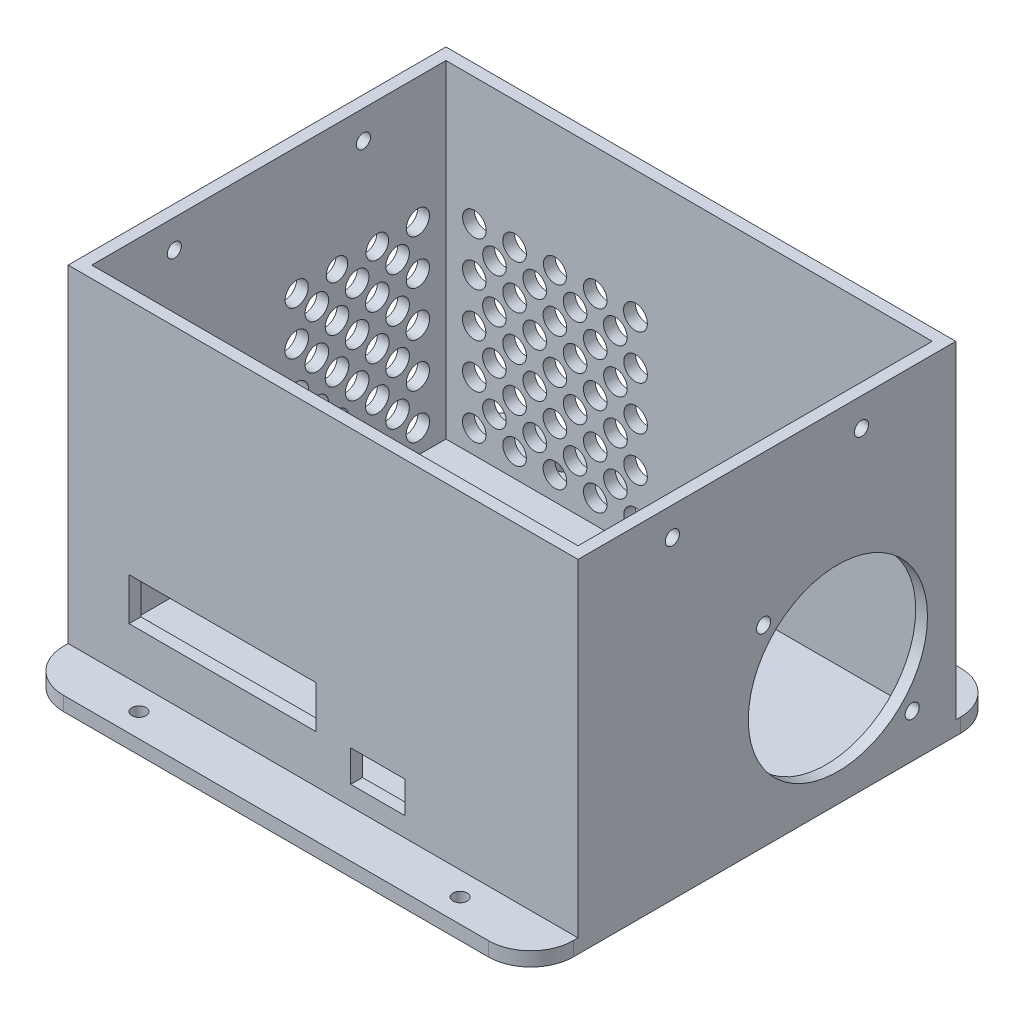
from build123d import *

# Parameters (mm, degrees)
SKETCH1_W                 = 78.1
SKETCH1_H                 = 55.9
BOSS_EXTRUDE1_DEPTH       = 3
SKETCH2_R                 = 1.25
CUT_EXTRUDE1_DEPTH        = 68
SKETCH4_W                 = 82.1
SKETCH4_H                 = 59.9
SKETCH4_W_2               = 78.1
SKETCH4_H_2               = 55.9
BOSS_EXTRUDE3_DEPTH       = 3
SKETCH6_R                 = 3
SKETCH6_R_2               = 1.25
BOSS_EXTRUDE4_DEPTH       = 3.5
SKETCH7_W                 = 82.1
SKETCH7_H                 = 16.2
BOSS_EXTRUDE5_DEPTH       = 3
SKETCH8_W                 = 82.1
SKETCH8_H                 = 50.5
BOSS_EXTRUDE6_DEPTH       = 3
BOSS_EXTRUDE7_DEPTH       = 20
SKETCH12_W                = 79.1
SKETCH12_H                = 50.5
BOSS_EXTRUDE8_DEPTH       = 3
SKETCH17_W                = 105.1
SKETCH17_H                = 50.5
BOSS_EXTRUDE13_DEPTH      = 1
BOSS_EXTRUDE13_DEPTH_BACK = 2
SKETCH18_W                = 11.5
SKETCH18_H                = 7.7
SKETCH18_W_2              = 39.6
SKETCH18_H_2              = 9
CUT_EXTRUDE4_DEPTH        = 9
SKETCH19_W                = 80.1
SKETCH19_H                = 50.5
BOSS_EXTRUDE14_DEPTH      = 3
SKETCH20_R                = 19
SKETCH20_R_2              = 1.5
CUT_EXTRUDE5_DEPTH        = 3
SKETCH22_R                = 2.5
CUT_EXTRUDE6_DEPTH        = 3
SKETCH23_W                = 108.1
SKETCH23_H                = 80.1
SKETCH23_W_2              = 102.1
SKETCH23_H_2              = 74.1
BOSS_EXTRUDE15_DEPTH      = 22
SKETCH24_R                = 1.5
CUT_EXTRUDE7_DEPTH        = 200
SKETCH25_R                = 2.5
CUT_EXTRUDE9_DEPTH        = 13.5
SKETCH26_W                = 103.1
SKETCH26_H                = 75.1
SKETCH26_W_2              = 102.1
SKETCH26_H_2              = 74.1
CUT_EXTRUDE13_DEPTH       = 69.5
SKETCH27_W                = 11.5
SKETCH27_H                = 1
BOSS_EXTRUDE17_DEPTH      = 2.5
SKETCH28_R                = 1.5
BOSS_EXTRUDE18_DEPTH      = 2.5
SKETCH30_R                = 2.5
SKETCH30_R_2              = 2.477942284
SKETCH30_R_3              = 2.503123049
SKETCH30_R_4              = 2.526952657
SKETCH30_R_5              = 2.451627817
CUT_EXTRUDE14_DEPTH       = 2.5
SKETCH32_W                = 38.749491288
SKETCH32_H                = 51.597296514
BOSS_EXTRUDE19_DEPTH      = 2.5
SKETCH33_R                = 2.482139688
SKETCH33_R_2              = 2.454549158
SKETCH33_R_3              = 2.5
SKETCH33_R_4              = 2.455770757
SKETCH33_R_5              = 2.390033197
SKETCH33_R_6              = 2.277845443
SKETCH33_R_7              = 2.451954558
CUT_EXTRUDE15_DEPTH       = 2.5
SKETCH34_W                = 108.1
SKETCH34_H                = 3
BOSS_EXTRUDE20_DEPTH      = 10
SKETCH35_W                = 108.1
SKETCH35_H                = 3
BOSS_EXTRUDE21_DEPTH      = 10
SKETCH36_R                = 1.5
CUT_EXTRUDE16_DEPTH       = 10
FILLET2_R                 = 9


with BuildPart() as part:
    # Sketch1 → Boss-Extrude1 (new body)
    with BuildSketch(Plane(origin=(0, 0, 0), x_dir=(1, 0, 0), z_dir=(0, 1, 0))):
        Rectangle(SKETCH1_W, SKETCH1_H)
    extrude(amount=BOSS_EXTRUDE1_DEPTH)

    # Sketch2 → Cut-Extrude1 (cut)
    with BuildSketch(Plane(origin=(0, 3, 0), x_dir=(1, 0, 0), z_dir=(0, 1, 0))):
        with Locations((-35.9, 20.9)):
            Circle(SKETCH2_R)
        with Locations((-35.9, -24.8)):
            Circle(SKETCH2_R)
        with Locations((35.9, -24.8)):
            Circle(SKETCH2_R)
        with Locations((35.9, 24.8)):
            Circle(SKETCH2_R)
    extrude(amount=-CUT_EXTRUDE1_DEPTH, mode=Mode.SUBTRACT)

    # Sketch4 → Boss-Extrude3 (add)
    with BuildSketch(Plane(origin=(0, 0, 0), x_dir=(-1, 0, 0), z_dir=(0, -1, 0))):
        Rectangle(SKETCH4_W, SKETCH4_H)
        Rectangle(SKETCH4_W_2, SKETCH4_H_2, mode=Mode.SUBTRACT)
    extrude(amount=-BOSS_EXTRUDE3_DEPTH)

    # Sketch6 → Boss-Extrude4 (add)
    with BuildSketch(Plane(origin=(0, 3, 0), x_dir=(1, 0, 0), z_dir=(0, 1, 0))):
        with Locations((-35.9, 20.9)):
            Circle(SKETCH6_R)
        with Locations((-35.9, 20.9)):
            Circle(SKETCH6_R_2, mode=Mode.SUBTRACT)
        with Locations((35.9, 24.8)):
            Circle(SKETCH6_R)
        with Locations((35.9, 24.8)):
            Circle(SKETCH6_R_2, mode=Mode.SUBTRACT)
        with Locations((35.9, -24.8)):
            Circle(SKETCH6_R)
        with Locations((35.9, -24.8)):
            Circle(SKETCH6_R_2, mode=Mode.SUBTRACT)
        with Locations((-35.9, -24.8)):
            Circle(SKETCH6_R)
        with Locations((-35.9, -24.8)):
            Circle(SKETCH6_R_2, mode=Mode.SUBTRACT)
    extrude(amount=BOSS_EXTRUDE4_DEPTH)

    # Sketch7 → Boss-Extrude5 (add)
    with BuildSketch(Plane(origin=(0, 0, 0), x_dir=(-1, 0, 0), z_dir=(0, -1, 0))):
        with Locations((0, 38.05)):
            Rectangle(SKETCH7_W, SKETCH7_H)
    extrude(amount=-BOSS_EXTRUDE5_DEPTH)

    # Sketch8 → Boss-Extrude6 (add)
    with BuildSketch(Plane(origin=(0, 0, -46.15), x_dir=(-1, 0, 0), z_dir=(0, 0, -1))):
        with Locations((0, 25.25)):
            Rectangle(SKETCH8_W, SKETCH8_H)
    extrude(amount=BOSS_EXTRUDE6_DEPTH)

    # Sketch10 → Boss-Extrude7 (add)
    with BuildSketch(Plane(origin=(41.05, 0, 0), x_dir=(0, 0, -1), z_dir=(1, 0, 0))):
        Polygon((49.15, 50.5), (46.15, 50.5), (46.15, 3), (-29.95, 3), (-29.95, 0), (49.15, 0), align=None)
    extrude(amount=BOSS_EXTRUDE7_DEPTH)

    # Sketch12 → Boss-Extrude8 (add)
    with BuildSketch(Plane.ZY.offset(41.05)):
        with Locations((-9.6, 25.25)):
            Rectangle(SKETCH12_W, SKETCH12_H)
    extrude(amount=BOSS_EXTRUDE8_DEPTH)

    # Sketch17 → Boss-Extrude13 (add, two sides)
    with BuildSketch(Plane.XY.offset(29.95)) as boss_extrude13_sk:
        with Locations((8.5, 25.25)):
            Rectangle(SKETCH17_W, SKETCH17_H)
    extrude(amount=BOSS_EXTRUDE13_DEPTH)
    extrude(boss_extrude13_sk.sketch, amount=-BOSS_EXTRUDE13_DEPTH_BACK)

    # Sketch18 → Cut-Extrude4 (cut)
    with BuildSketch(Plane(origin=(0, 0, 27.95), x_dir=(-1, 0, 0), z_dir=(0, 0, -1))):
        with Locations((-21.6, 9.95)):
            Rectangle(SKETCH18_W, SKETCH18_H)
        with Locations((11.35, 17.6)):
            Rectangle(SKETCH18_W_2, SKETCH18_H_2)
    extrude(amount=-CUT_EXTRUDE4_DEPTH, mode=Mode.SUBTRACT)

    # Sketch19 → Boss-Extrude14 (add)
    with BuildSketch(Plane(origin=(61.05, 0, 0), x_dir=(0, 0, -1), z_dir=(1, 0, 0))):
        with Locations((9.1, 25.25)):
            Rectangle(SKETCH19_W, SKETCH19_H)
    extrude(amount=BOSS_EXTRUDE14_DEPTH)

    # Sketch20 → Cut-Extrude5 (cut)
    with BuildSketch(Plane.ZY.offset(-61.05)):
        with Locations((-24.15, 25)):
            Circle(SKETCH20_R)
        with Locations((-8.4, 40.75)):
            Circle(SKETCH20_R_2)
        with Locations((-39.9, 40.75)):
            Circle(SKETCH20_R_2)
        with Locations((-8.4, 9.25)):
            Circle(SKETCH20_R_2)
        with Locations((-39.9, 9.25)):
            Circle(SKETCH20_R_2)
    extrude(amount=-CUT_EXTRUDE5_DEPTH, mode=Mode.SUBTRACT)

    # Sketch22 → Cut-Extrude6 (cut)
    with BuildSketch(Plane(origin=(-41.05, 0, 0), x_dir=(0, 0, -1), z_dir=(1, 0, 0))):
        with Locations((14.225, 12.6875)):
            Circle(SKETCH22_R)
        with Locations((14.225, 22.0625)):
            Circle(SKETCH22_R)
        with Locations((18.5, 17.375)):
            Circle(SKETCH22_R)
        with Locations((22.775, 22.0625)):
            Circle(SKETCH22_R)
        with Locations((22.775, 12.6875)):
            Circle(SKETCH22_R)
        with Locations((14.225, 31.4375)):
            Circle(SKETCH22_R)
        with Locations((18.5, 26.75)):
            Circle(SKETCH22_R)
        with Locations((22.775, 31.4375)):
            Circle(SKETCH22_R)
        with Locations((18.5, 36.125)):
            Circle(SKETCH22_R)
        with Locations((14.225, 40.8125)):
            Circle(SKETCH22_R)
        with Locations((22.775, 40.8125)):
            Circle(SKETCH22_R)
        with Locations((27.05, 36.125)):
            Circle(SKETCH22_R)
        with Locations((31.325, 40.8125)):
            Circle(SKETCH22_R)
        with Locations((39.875, 40.8125)):
            Circle(SKETCH22_R)
        with Locations((35.6, 36.125)):
            Circle(SKETCH22_R)
        with Locations((39.875, 31.4375)):
            Circle(SKETCH22_R)
        with Locations((31.325, 31.4375)):
            Circle(SKETCH22_R)
        with Locations((27.05, 26.75)):
            Circle(SKETCH22_R)
        with Locations((31.325, 22.0625)):
            Circle(SKETCH22_R)
        with Locations((39.875, 22.0625)):
            Circle(SKETCH22_R)
        with Locations((35.6, 26.75)):
            Circle(SKETCH22_R)
        with Locations((27.05, 17.375)):
            Circle(SKETCH22_R)
        with Locations((31.325, 12.6875)):
            Circle(SKETCH22_R)
        with Locations((39.875, 12.6875)):
            Circle(SKETCH22_R)
        with Locations((35.6, 17.375)):
            Circle(SKETCH22_R)
        with Locations((18.5, 8)):
            Circle(SKETCH22_R)
        with Locations((27.05, 8)):
            Circle(SKETCH22_R)
        with Locations((35.6, 8)):
            Circle(SKETCH22_R)
    extrude(amount=-CUT_EXTRUDE6_DEPTH, mode=Mode.SUBTRACT)

    # Sketch23 → Boss-Extrude15 (add)
    with BuildSketch(Plane(origin=(0, 50.5, 0), x_dir=(1, 0, 0), z_dir=(0, 1, 0))):
        with Locations((10, 9.1)):
            Rectangle(SKETCH23_W, SKETCH23_H)
        with Locations((10, 9.1)):
            Rectangle(SKETCH23_W_2, SKETCH23_H_2, mode=Mode.SUBTRACT)
    extrude(amount=BOSS_EXTRUDE15_DEPTH)

    # Sketch24 → Cut-Extrude7 (cut)
    with BuildSketch(Plane.ZY.offset(44.05)):
        with Locations((-29.15, 66.5)):
            Circle(SKETCH24_R)
        with Locations((10.95, 66.5)):
            Circle(SKETCH24_R)
    extrude(amount=-CUT_EXTRUDE7_DEPTH, mode=Mode.SUBTRACT)

    # Sketch25 → Cut-Extrude9 (cut)
    with BuildSketch(Plane.ZY.offset(44.05)):
        with Locations((-35.6, 45.5)):
            Circle(SKETCH25_R)
        with Locations((-27.05, 45.5)):
            Circle(SKETCH25_R)
        with Locations((-18.5, 45.5)):
            Circle(SKETCH25_R)
    extrude(amount=-CUT_EXTRUDE9_DEPTH, mode=Mode.SUBTRACT)

    # Sketch26 → Cut-Extrude13 (cut)
    with BuildSketch(Plane(origin=(0, 72.5, 0), x_dir=(1, 0, 0), z_dir=(0, 1, 0))):
        with Locations((10, 9.1)):
            Rectangle(SKETCH26_W, SKETCH26_H)
        with Locations((10, 9.1)):
            Rectangle(SKETCH26_W_2, SKETCH26_H_2, mode=Mode.SUBTRACT)
    extrude(amount=-CUT_EXTRUDE13_DEPTH, mode=Mode.SUBTRACT)

    # Sketch27 → Boss-Extrude17 (add)
    with BuildSketch(Plane.XY.offset(30.95)):
        with Locations((21.6, 6.6)):
            Rectangle(SKETCH27_W, SKETCH27_H)
    extrude(amount=-BOSS_EXTRUDE17_DEPTH)

    # Sketch28 → Boss-Extrude18 (add)
    with BuildSketch(Plane(origin=(64.05, 0, 0), x_dir=(0, 0, -1), z_dir=(1, 0, 0))):
        with Locations((39.9, 40.75)):
            Circle(SKETCH28_R)
        with Locations((8.4, 9.25)):
            Circle(SKETCH28_R)
    extrude(amount=-BOSS_EXTRUDE18_DEPTH)

    # Sketch30 → Cut-Extrude14 (cut)
    with BuildSketch(Plane(origin=(0, 0, -49.15), x_dir=(-1, 0, 0), z_dir=(0, 0, -1))):
        with Locations((35.55, 8)):
            Circle(SKETCH30_R)
        with Locations((27, 8)):
            Circle(SKETCH30_R)
        with Locations((18.45, 8)):
            Circle(SKETCH30_R)
        with Locations((9.9, 8)):
            Circle(SKETCH30_R)
        with Locations((1.35, 8)):
            Circle(SKETCH30_R)
        with Locations((5.61949352, 12.693537807)):
            Circle(SKETCH30_R)
        with Locations((14.16949352, 12.693537807)):
            Circle(SKETCH30_R)
        with Locations((22.725, 12.6875)):
            Circle(SKETCH30_R)
        with Locations((31.275, 12.6875)):
            Circle(SKETCH30_R)
        with Locations((27, 17.375)):
            Circle(SKETCH30_R)
        with Locations((35.55, 17.375)):
            Circle(SKETCH30_R)
        with Locations((35.572057716, 26.774186092)):
            Circle(SKETCH30_R_2)
        with Locations((35.55, 36.125)):
            Circle(SKETCH30_R_3)
        with Locations((35.525916159, 45.521964463)):
            Circle(SKETCH30_R)
        with Locations((1.35, 17.375)):
            Circle(SKETCH30_R)
        with Locations((1.327942284, 26.774186092)):
            Circle(SKETCH30_R_2)
        with Locations((1.35, 36.125)):
            Circle(SKETCH30_R)
        with Locations((1.376952657, 45.524580823)):
            Circle(SKETCH30_R_4)
        with Locations((18.45, 45.548372183)):
            Circle(SKETCH30_R_5)
        with Locations((9.9, 45.5)):
            Circle(SKETCH30_R)
        with Locations((27, 45.5)):
            Circle(SKETCH30_R)
        with Locations((27, 36.173372183)):
            Circle(SKETCH30_R)
        with Locations((18.452627468, 36.176253179)):
            Circle(SKETCH30_R)
        with Locations((9.902627468, 36.176253179)):
            Circle(SKETCH30_R)
        with Locations((9.902627468, 26.801253179)):
            Circle(SKETCH30_R)
        with Locations((18.452627468, 26.801253179)):
            Circle(SKETCH30_R)
        with Locations((27, 26.75)):
            Circle(SKETCH30_R)
        with Locations((18.45, 17.375)):
            Circle(SKETCH30_R)
        with Locations((9.88898704, 17.387075614)):
            Circle(SKETCH30_R)
        with Locations((5.608464662, 22.080630853)):
            Circle(SKETCH30_R)
        with Locations((14.170807254, 22.094164396)):
            Circle(SKETCH30_R)
        with Locations((22.726313734, 22.088126589)):
            Circle(SKETCH30_R)
        with Locations((31.286028858, 22.074593046)):
            Circle(SKETCH30_R)
        with Locations((31.286028858, 31.473779137)):
            Circle(SKETCH30_R)
        with Locations((31.26295808, 40.847668323)):
            Circle(SKETCH30_R)
        with Locations((22.725, 40.8125)):
            Circle(SKETCH30_R)
        with Locations((22.726313734, 31.487312681)):
            Circle(SKETCH30_R)
        with Locations((14.177627468, 31.488753179)):
            Circle(SKETCH30_R)
        with Locations((14.176313734, 40.862312681)):
            Circle(SKETCH30_R)
        with Locations((5.639790062, 40.850417001)):
            Circle(SKETCH30_R)
        with Locations((5.615284876, 31.475219635)):
            Circle(SKETCH30_R)
    extrude(amount=-CUT_EXTRUDE14_DEPTH, mode=Mode.SUBTRACT)

    # Sketch32 → Boss-Extrude19 (add)
    with BuildSketch(Plane.ZY.offset(44.05)):
        with Locations((-25.509986605, 28.814988894)):
            Rectangle(SKETCH32_W, SKETCH32_H)
    extrude(amount=-BOSS_EXTRUDE19_DEPTH)

    # Sketch33 → Cut-Extrude15 (cut)
    with BuildSketch(Plane.ZY.offset(44.05)):
        with Locations((-40.690817502, 8.026993726)):
            Circle(SKETCH33_R)
        with Locations((-40.690817502, 17.480391526)):
            Circle(SKETCH33_R_2)
        with Locations((-40.690817502, 26.876134795)):
            Circle(SKETCH33_R_3)
        with Locations((-40.690817502, 36.327449599)):
            Circle(SKETCH33_R_4)
        with Locations((-40.690817502, 45.834664619)):
            Circle(SKETCH33_R_2)
        with Locations((-32.095987762, 45.609966803)):
            Circle(SKETCH33_R_5)
        with Locations((-23.545126385, 45.722154557)):
            Circle(SKETCH33_R_6)
        with Locations((-15.001944115, 45.548045442)):
            Circle(SKETCH33_R_7)
        with Locations((-36.391519127, 41.081057109)):
            Circle(SKETCH33_R_3)
        with Locations((-27.818673568, 41.024802078)):
            Circle(SKETCH33_R_3)
        with Locations((-19.272048586, 40.996497097)):
            Circle(SKETCH33_R_3)
        with Locations((-14.998970787, 36.270839637)):
            Circle(SKETCH33_R_3)
        with Locations((-14.999909763, 26.818480265)):
            Circle(SKETCH33_R_3)
        with Locations((-14.997081728, 17.423775422)):
            Circle(SKETCH33_R_3)
        with Locations((-14.999909763, 8.026993726)):
            Circle(SKETCH33_R_3)
        with Locations((-23.544181752, 8.026993726)):
            Circle(SKETCH33_R_3)
        with Locations((-32.092220751, 8.026993726)):
            Circle(SKETCH33_R)
        with Locations((-32.092220751, 17.480391526)):
            Circle(SKETCH33_R_3)
        with Locations((-32.092220751, 26.876134795)):
            Circle(SKETCH33_R_3)
        with Locations((-23.544181752, 26.876134795)):
            Circle(SKETCH33_R_3)
        with Locations((-23.544181752, 17.480391526)):
            Circle(SKETCH33_R_3)
        with Locations((-36.391519127, 31.601792197)):
            Circle(SKETCH33_R_3)
        with Locations((-27.818201252, 31.601792197)):
            Circle(SKETCH33_R_3)
        with Locations((-23.544181752, 36.327449599)):
            Circle(SKETCH33_R_3)
        with Locations((-19.271576269, 31.573487216)):
            Circle(SKETCH33_R_3)
        with Locations((-27.818201252, 22.17826316)):
            Circle(SKETCH33_R_3)
        with Locations((-36.391519127, 22.17826316)):
            Circle(SKETCH33_R_3)
        with Locations((-36.375, 12.6875)):
            Circle(SKETCH33_R_3)
        with Locations((-27.818201252, 12.753692626)):
            Circle(SKETCH33_R_3)
        with Locations((-19.27063174, 12.725384574)):
            Circle(SKETCH33_R_3)
        with Locations((-19.27063174, 22.149955108)):
            Circle(SKETCH33_R_3)
        with Locations((-32.092220751, 36.327449599)):
            Circle(SKETCH33_R_3)
    extrude(amount=-CUT_EXTRUDE15_DEPTH, mode=Mode.SUBTRACT)

    # Sketch34 → Boss-Extrude20 (add)
    with BuildSketch(Plane.XY.offset(30.95)):
        with Locations((10, 1.5)):
            Rectangle(SKETCH34_W, SKETCH34_H)
    extrude(amount=BOSS_EXTRUDE20_DEPTH)

    # Sketch35 → Boss-Extrude21 (add)
    with BuildSketch(Plane(origin=(0, 0, -49.15), x_dir=(-1, 0, 0), z_dir=(0, 0, -1))):
        with Locations((-10, 1.5)):
            Rectangle(SKETCH35_W, SKETCH35_H)
    extrude(amount=BOSS_EXTRUDE21_DEPTH)

    # Sketch36 → Cut-Extrude16 (cut)
    with BuildSketch(Plane(origin=(0, 3, 0), x_dir=(1, 0, 0), z_dir=(0, 1, 0))):
        with Locations((44.05, 54.15)):
            Circle(SKETCH36_R)
        with Locations((-24.05, 54.15)):
            Circle(SKETCH36_R)
        with Locations((44.05, -35.95)):
            Circle(SKETCH36_R)
        with Locations((-24.05, -35.95)):
            Circle(SKETCH36_R)
    extrude(amount=-CUT_EXTRUDE16_DEPTH, mode=Mode.SUBTRACT)

    # Fillet2
    fillet2_edges = [part.edges().sort_by_distance(p)[0] for p in [
        (-44.05, 1.5, 40.95),
        (64.05, 1.5, 40.95),
        (64.05, 1.5, -59.15),
        (-44.05, 1.5, -59.15),
    ]]
    fillet(fillet2_edges, radius=FILLET2_R)


solid = part.part
